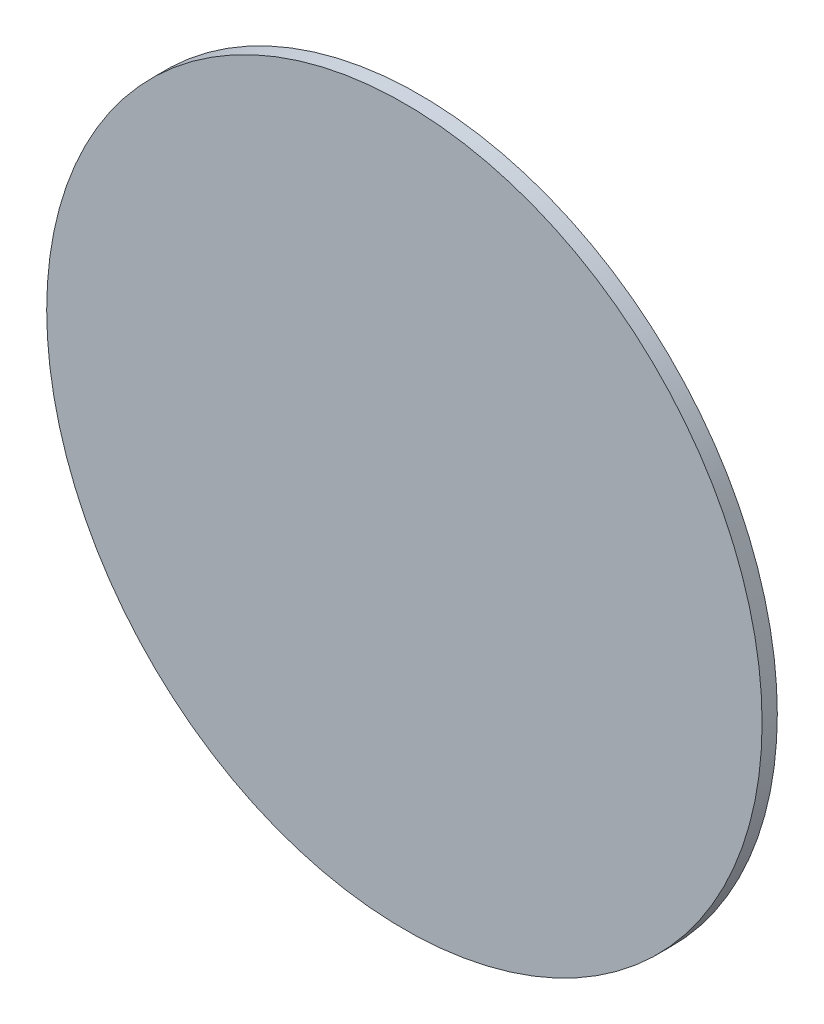
from build123d import *

# Parameters (mm, degrees)
SKETCH1_R           = 5.969
BOSS_EXTRUDE1_DEPTH = 0.254


with BuildPart() as part:
    # Sketch1 → Boss-Extrude1 (new body)
    with BuildSketch(Plane.XY):
        Circle(SKETCH1_R)
    extrude(amount=BOSS_EXTRUDE1_DEPTH)


solid = part.part
